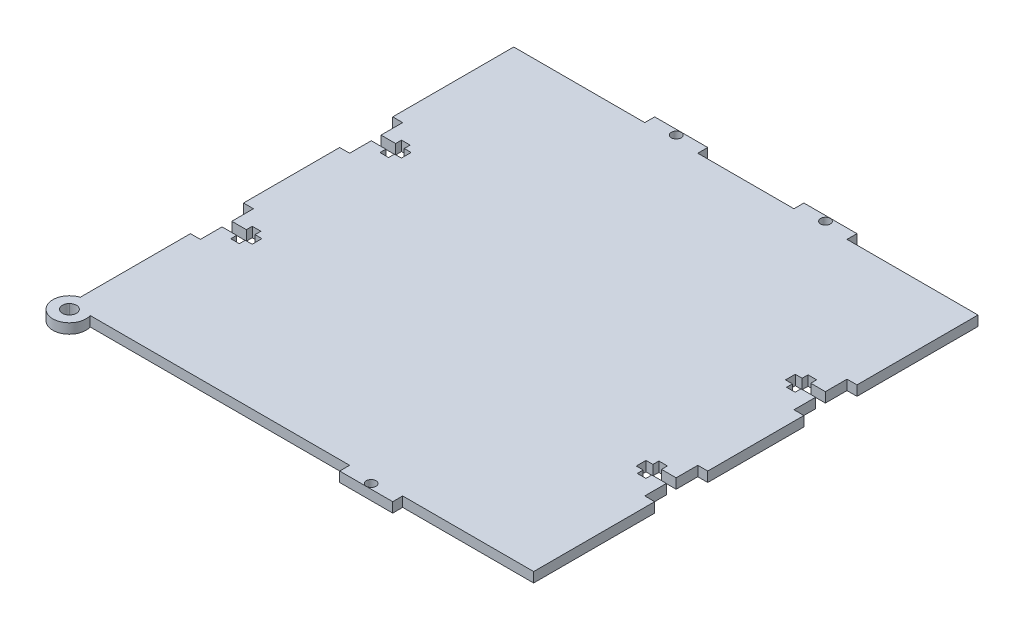
from build123d import *

# Parameters (mm, degrees)
SKETCH1_W           = 140
SKETCH1_H           = 140
BOSS_EXTRUDE1_DEPTH = 3
SKETCH2_W           = 39.5
SKETCH2_H           = 3
SKETCH2_W_2         = 29
CUT_EXTRUDE2_DEPTH  = 3
SKETCH4_W           = 3
SKETCH4_H           = 16
CUT_EXTRUDE3_DEPTH  = 3
SKETCH6_R           = 1.47
CUT_EXTRUDE4_DEPTH  = 4
CUT_EXTRUDE5_DEPTH  = 3
SKETCH8_W           = 16
SKETCH8_H           = 3
CUT_EXTRUDE6_DEPTH  = 3
SKETCH9_R           = 5
BOSS_EXTRUDE3_DEPTH = 3
SKETCH10_R          = 2.12
CUT_EXTRUDE7_DEPTH  = 3


with BuildPart() as part:
    # Sketch1 → Boss-Extrude1 (new body)
    with BuildSketch(Plane(origin=(0, 0, 0), x_dir=(1, 0, 0), z_dir=(0, 1, 0))):
        Rectangle(SKETCH1_W, SKETCH1_H)
    extrude(amount=BOSS_EXTRUDE1_DEPTH)

    # Sketch2 → Cut-Extrude2 (cut)
    with BuildSketch(Plane(origin=(0, 3, 0), x_dir=(1, 0, 0), z_dir=(0, 1, 0))):
        with Locations((-50.25, 68.5)):
            Rectangle(SKETCH2_W, SKETCH2_H)
        with Locations((-50.25, -68.5)):
            Rectangle(SKETCH2_W, SKETCH2_H)
        with Locations((50.25, -68.5)):
            Rectangle(SKETCH2_W, SKETCH2_H)
        with Locations((50.25, 68.5)):
            Rectangle(SKETCH2_W, SKETCH2_H)
        with Locations((0, 68.5)):
            Rectangle(SKETCH2_W_2, SKETCH2_H)
        with Locations((0, -68.5)):
            Rectangle(SKETCH2_W_2, SKETCH2_H)
    extrude(amount=-CUT_EXTRUDE2_DEPTH, mode=Mode.SUBTRACT)

    # Sketch4 → Cut-Extrude3 (cut)
    with BuildSketch(Plane(origin=(0, 3, 0), x_dir=(1, 0, 0), z_dir=(0, 1, 0))):
        with Locations((-68.5, 22.5)):
            Rectangle(SKETCH4_W, SKETCH4_H)
        with Locations((-68.5, -22.5)):
            Rectangle(SKETCH4_W, SKETCH4_H)
        with Locations((68.5, 22.5)):
            Rectangle(SKETCH4_W, SKETCH4_H)
        with Locations((68.5, -22.5)):
            Rectangle(SKETCH4_W, SKETCH4_H)
    extrude(amount=-CUT_EXTRUDE3_DEPTH, mode=Mode.SUBTRACT)

    # Sketch6 → Cut-Extrude4 (cut, through all)
    with BuildSketch(Plane.XZ):
        with Locations((-22.5, 68.5)):
            Circle(SKETCH6_R)
        with Locations((22.5, 68.5)):
            Circle(SKETCH6_R)
    cut_extrude4 = extrude(amount=-CUT_EXTRUDE4_DEPTH, mode=Mode.SUBTRACT)

    # Mirror1: Cut-Extrude4 across plane
    add(cut_extrude4.mirror(Plane.XY), mode=Mode.SUBTRACT)

    # Sketch7 → Cut-Extrude5 (cut)
    with BuildSketch(Plane(origin=(0, 0, 0), x_dir=(-1, 0, 0), z_dir=(0, -1, 0))):
        Polygon((67, -23.97), (62.6, -23.97), (62.6, -25.75), (60, -25.75), (60, -23.97), (57.92, -23.97), (57.92, -21.03), (60, -21.03), (60, -19.25), (62.6, -19.25), (62.6, -21.03), (67, -21.03), align=None)
        Polygon((-67, -23.97), (-67, -21.03), (-62.6, -21.03), (-62.6, -19.25), (-60, -19.25), (-60, -21.03), (-57.92, -21.03), (-57.92, -23.97), (-60, -23.97), (-60, -25.75), (-62.6, -25.75), (-62.6, -23.97), align=None)
        Polygon((-67, 23.97), (-62.6, 23.97), (-62.6, 25.75), (-60, 25.75), (-60, 23.97), (-57.92, 23.97), (-57.92, 21.03), (-60, 21.03), (-60, 19.25), (-62.6, 19.25), (-62.6, 21.03), (-67, 21.03), align=None)
        Polygon((67, 23.97), (67, 21.03), (62.6, 21.03), (62.6, 19.25), (60, 19.25), (60, 21.03), (57.92, 21.03), (57.92, 23.97), (60, 23.97), (60, 25.75), (62.6, 25.75), (62.6, 23.97), align=None)
    extrude(amount=-CUT_EXTRUDE5_DEPTH, mode=Mode.SUBTRACT)

    # Sketch8 → Cut-Extrude6 (cut)
    with BuildSketch(Plane(origin=(0, 0, 0), x_dir=(-1, 0, 0), z_dir=(0, -1, 0))):
        with Locations((22.5, -68.5)):
            Rectangle(SKETCH8_W, SKETCH8_H)
    extrude(amount=-CUT_EXTRUDE6_DEPTH, mode=Mode.SUBTRACT)

    # Sketch9 → Boss-Extrude3 (add)
    with BuildSketch(Plane(origin=(0, 0, 0), x_dir=(-1, 0, 0), z_dir=(0, -1, 0))):
        with Locations((68.5, -68.5)):
            Circle(SKETCH9_R)
        with BuildLine():
            ThreePointArc((67.00186783, -67), (67.000933624, -67.000933624), (67, -67.00186783))
            Line((67, -67.00186783), (67, -67))
            Line((67, -67), (67.00186783, -67))
        make_face(mode=Mode.SUBTRACT)
        with BuildLine():
            ThreePointArc((67.00186783, -67), (68.5, -66.38), (69.99813217, -67))
            Line((69.99813217, -67), (67.00186783, -67))
        make_face(mode=Mode.SUBTRACT)
        with BuildLine():
            Line((69.99813217, -67), (70, -67))
            Line((70, -67), (70, -67.00186783))
            ThreePointArc((70, -67.00186783), (69.999066376, -67.000933624), (69.99813217, -67))
        make_face(mode=Mode.SUBTRACT)
    extrude(amount=-BOSS_EXTRUDE3_DEPTH)

    # Sketch10 → Cut-Extrude7 (cut)
    with BuildSketch(Plane(origin=(0, 3, 0), x_dir=(1, 0, 0), z_dir=(0, 1, 0))):
        with Locations((-68.5, -68.5)):
            Circle(SKETCH10_R)
    extrude(amount=-CUT_EXTRUDE7_DEPTH, mode=Mode.SUBTRACT)


solid = part.part
